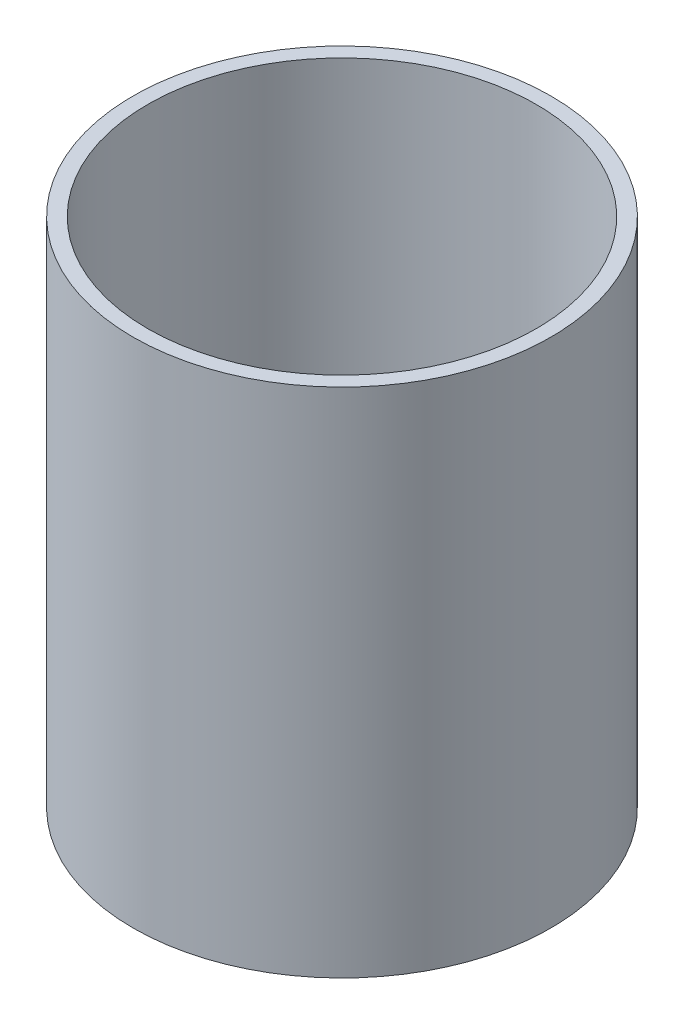
from build123d import *

# Parameters (mm, degrees)
ESBO_O1_R                = 57.15
ESBO_O1_R_2              = 53.15
RESSALTO_EXTRUS_O1_DEPTH = 140


with BuildPart() as part:
    # Esboço1 → Ressalto-extrusão1 (new body)
    with BuildSketch(Plane(origin=(0, 0, 0), x_dir=(1, 0, 0), z_dir=(0, 1, 0))):
        Circle(ESBO_O1_R)
        Circle(ESBO_O1_R_2, mode=Mode.SUBTRACT)
    extrude(amount=RESSALTO_EXTRUS_O1_DEPTH)


solid = part.part
